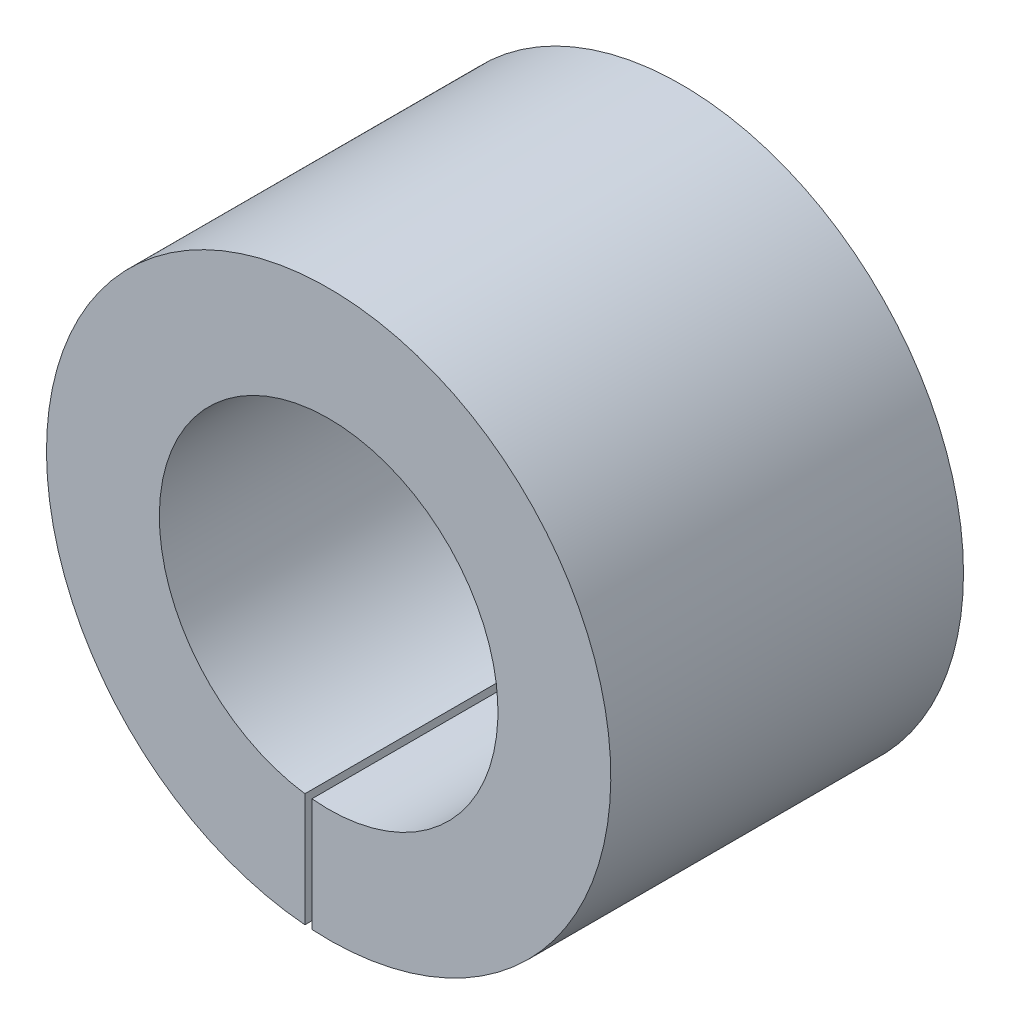
from build123d import *

# Parameters (mm, degrees)
SKETCH_1_R          = 20
SKETCH_1_R_2        = 12
EXTRUDE_1_DEPTH     = 25
SKETCH_2_W          = 0.5
SKETCH_2_H          = 19.301562603
CUT_EXTRUDE_1_DEPTH = 15
SKETCH_3_W          = 0.5
SKETCH_3_H          = 20.813345434
CUT_EXTRUDE_2_DEPTH = 15


with BuildPart() as part:
    # 草图1 → 凸台-拉伸1 (new body)
    with BuildSketch(Plane.XY):
        Circle(SKETCH_1_R)
        Circle(SKETCH_1_R_2, mode=Mode.SUBTRACT)
    extrude(amount=EXTRUDE_1_DEPTH)

    # 草图2 → 切除-拉伸1 (cut)
    with BuildSketch(Plane.XY.offset(25)):
        with Locations((-1.434574757, -11.913941214)):
            Rectangle(SKETCH_2_W, SKETCH_2_H)
    extrude(amount=-CUT_EXTRUDE_1_DEPTH, mode=Mode.SUBTRACT)

    # 草图3 → 切除-拉伸2 (cut)
    with BuildSketch(Plane(origin=(0, 0, 0), x_dir=(-1, 0, 0), z_dir=(0, 0, -1))):
        with Locations((-0.669659449, 7.720299062)):
            Rectangle(SKETCH_3_W, SKETCH_3_H)
    extrude(amount=-CUT_EXTRUDE_2_DEPTH, mode=Mode.SUBTRACT)


solid = part.part
